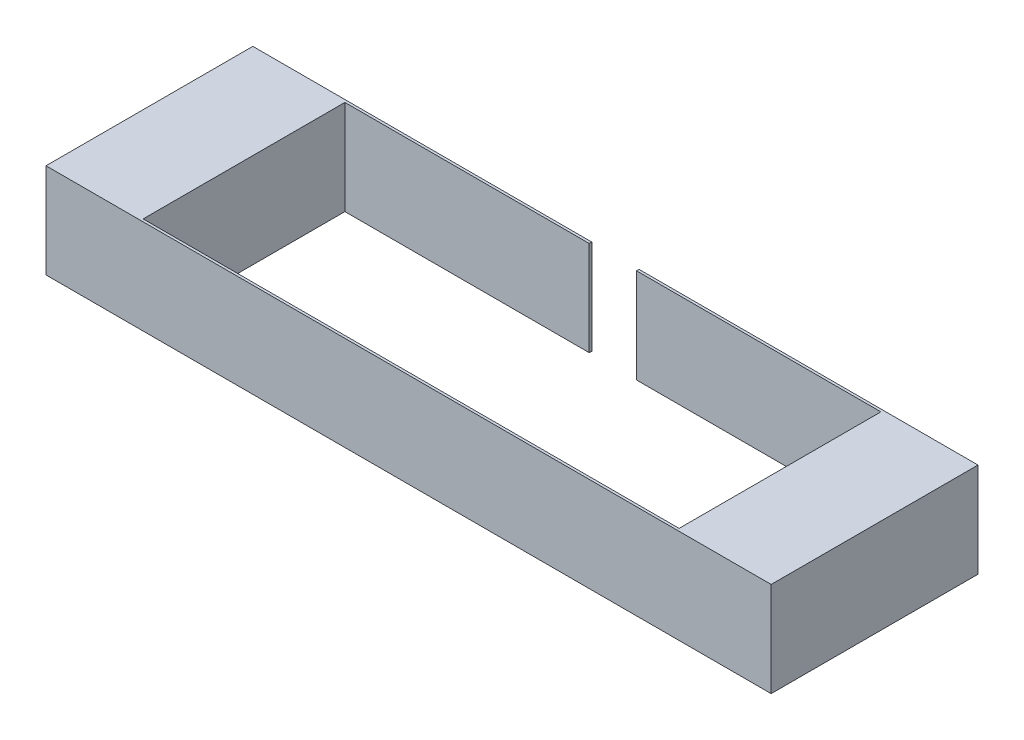
from build123d import *

# Parameters (mm, degrees)
SKETCH1_W             = 1.016
SKETCH1_H             = 38.1
BOSS_EXTRUDE2_DEPTH   = 107.95
BOSS_EXTRUDE2_2_DEPTH = 107.95
SKETCH2_W             = 38.1
SKETCH2_H             = 38.1
BOSS_EXTRUDE3_DEPTH   = 83.312
CUT_EXTRUDE1_REACH    = 85.312
SKETCH3_W             = 19.05
SKETCH3_H             = 38.1


with BuildPart() as part:
    # Sketch1 → Boss-Extrude2 (new body, symmetric)
    with BuildSketch(Plane(origin=(0, 0, 0), x_dir=(0, 0, -1), z_dir=(1, 0, 0))):
        with Locations((41.148, 0)):
            Rectangle(SKETCH1_W, SKETCH1_H)
    extrude(amount=BOSS_EXTRUDE2_DEPTH, both=True)



with BuildPart() as body_2:
    # Sketch1 → Boss-Extrude2 2 (new body, symmetric)
    with BuildSketch(Plane(origin=(0, 0, 0), x_dir=(0, 0, -1), z_dir=(1, 0, 0))):
        with Locations((-41.148, 0)):
            Rectangle(SKETCH1_W, SKETCH1_H)
    extrude(amount=BOSS_EXTRUDE2_2_DEPTH, both=True)


with BuildPart() as part_1:
    add(part.part)

    add(body_2.part)  # Boss-Extrude3 merges body 2
    # Sketch2 → Boss-Extrude3 (add)
    with BuildSketch(Plane.XY.offset(41.656)):
        with Locations((127, 0)):
            Rectangle(SKETCH2_W, SKETCH2_H)
    boss_extrude3 = extrude(amount=-BOSS_EXTRUDE3_DEPTH)

    # Mirror4: Boss-Extrude3 across plane
    add(boss_extrude3.mirror(Plane(origin=(0, 0, 0), x_dir=(0, 0, 1), z_dir=(1, 0, 0))))

    # Sketch3 → Cut-Extrude1 (cut, up to next)
    with BuildSketch(Plane(origin=(0, 0, -41.656), x_dir=(-1, 0, 0), z_dir=(0, 0, -1)), mode=Mode.PRIVATE) as cut_extrude1_sk1:
        Rectangle(SKETCH3_W, SKETCH3_H)
    cut_extrude1_tool1 = extrude(cut_extrude1_sk1.sketch, amount=-CUT_EXTRUDE1_REACH, mode=Mode.PRIVATE) & part_1.part
    add(cut_extrude1_tool1.solids().sort_by_distance((0, 0, -41.656))[0], mode=Mode.SUBTRACT)


solid = part_1.part
